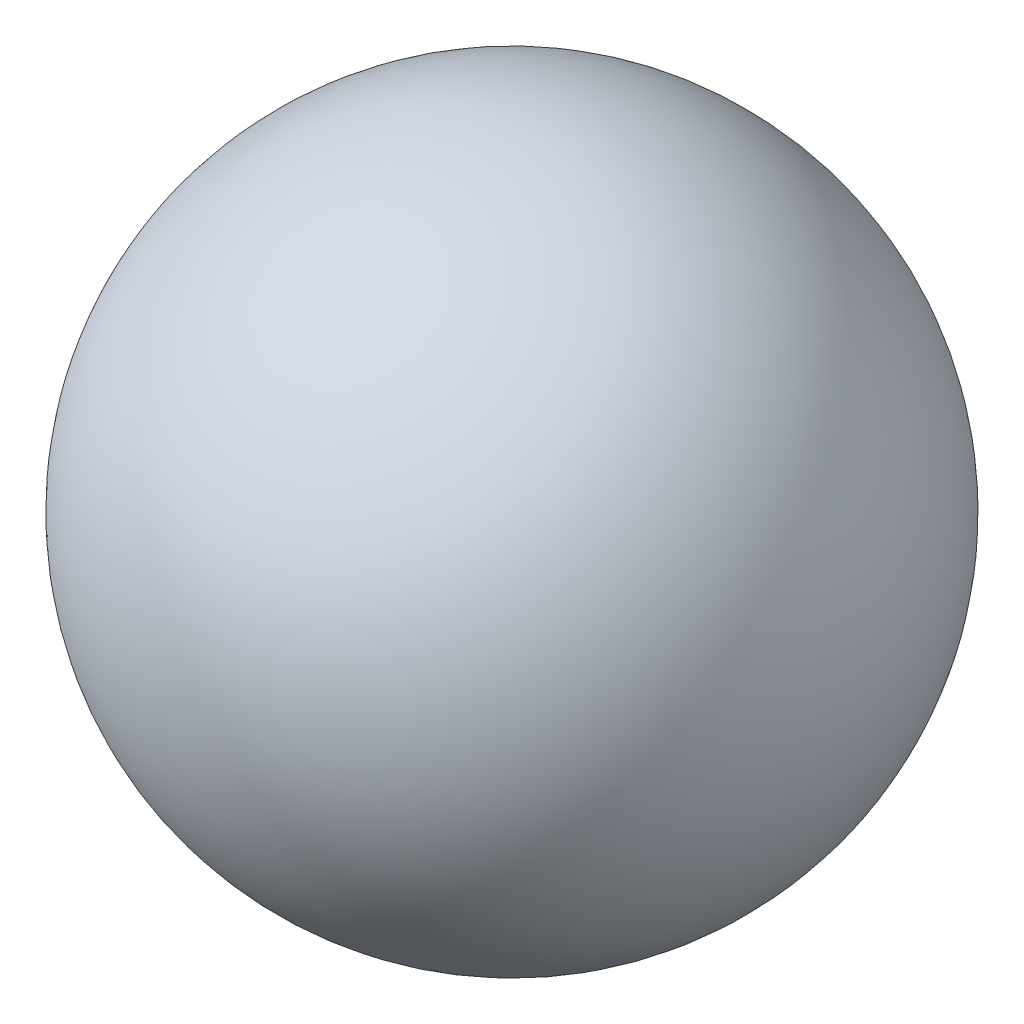
from build123d import *


with BuildPart() as part:
    # Sketch1 → Revolve1 (revolve)
    with BuildSketch(Plane.XY):
        with BuildLine():
            Line((-1, 0), (1, 0))
            ThreePointArc((1, 0), (0, 1), (-1, 0))
        make_face()
    revolve(axis=Axis((-1, 0, 0), (1, 0, 0)))


solid = part.part
